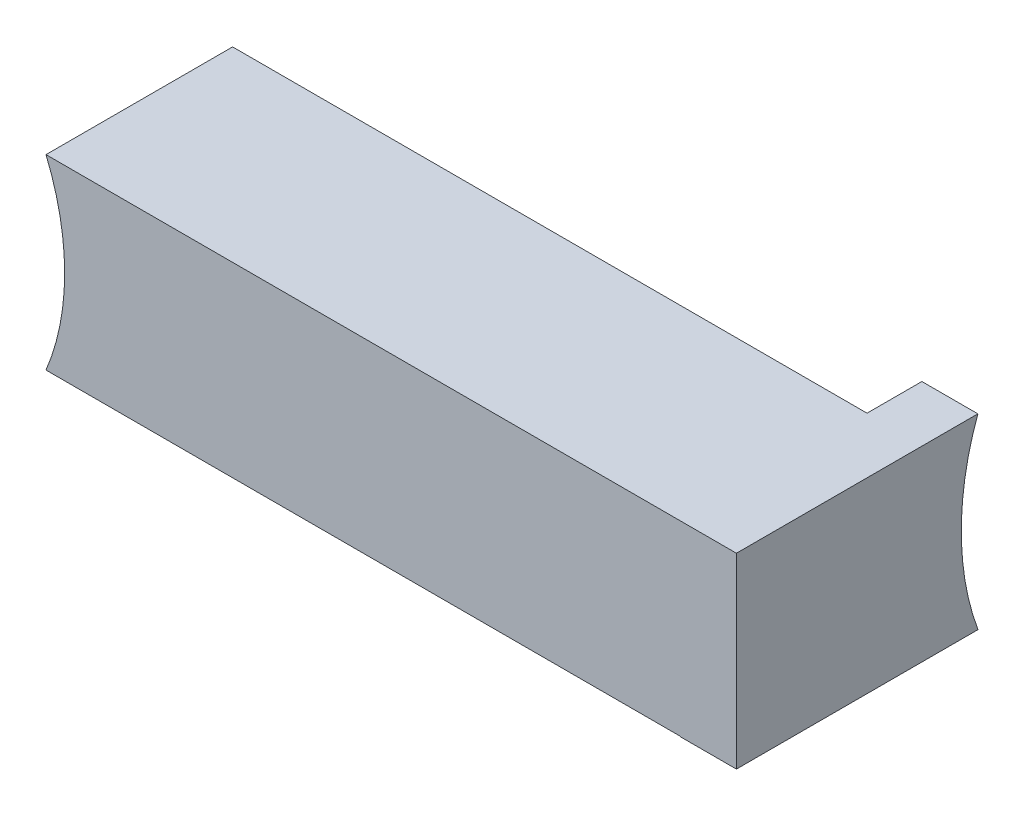
from build123d import *

# Parameters (mm, degrees)
ESBO_O1_W             = 10
ESBO_O1_H             = 10
EXTRUS_O1_DEPTH       = 40
ESBO_O2_W             = 14.229592149
ESBO_O2_H             = 10.020208066
EXTRUS_O2_DEPTH       = 3
ESBO_O3_R             = 14.5
CORTE_EXTRUS_O1_DEPTH = 23
ESBO_O4_R             = 13
CORTE_EXTRUS_O2_DEPTH = 23


with BuildPart() as part:
    # Esboço1 → Extrusão1 (new body)
    with BuildSketch(Plane(origin=(0, 0, 0), x_dir=(0, 0, -1), z_dir=(1, 0, 0))):
        Rectangle(ESBO_O1_W, ESBO_O1_H)
    extrude(amount=-EXTRUS_O1_DEPTH)

    # Esboço2 → Extrusão2 (add)
    with BuildSketch(Plane(origin=(0, 0, 0), x_dir=(0, 0, -1), z_dir=(1, 0, 0))):
        with Locations((2.114796075, -0.010104033)):
            Rectangle(ESBO_O2_W, ESBO_O2_H)
    extrude(amount=-EXTRUS_O2_DEPTH)

    # Esboço3 → Corte-extrusão1 (cut)
    with BuildSketch(Plane(origin=(0, 0, 0), x_dir=(0, 0, -1), z_dir=(1, 0, 0))):
        with Locations((21.55, 0)):
            Circle(ESBO_O3_R)
    extrude(amount=-CORTE_EXTRUS_O1_DEPTH, mode=Mode.SUBTRACT)

    # Esboço4 → Corte-extrusão2 (cut)
    with BuildSketch(Plane.XY.offset(5)):
        with Locations((-49, 0)):
            Circle(ESBO_O4_R)
    extrude(amount=-CORTE_EXTRUS_O2_DEPTH, mode=Mode.SUBTRACT)


solid = part.part
